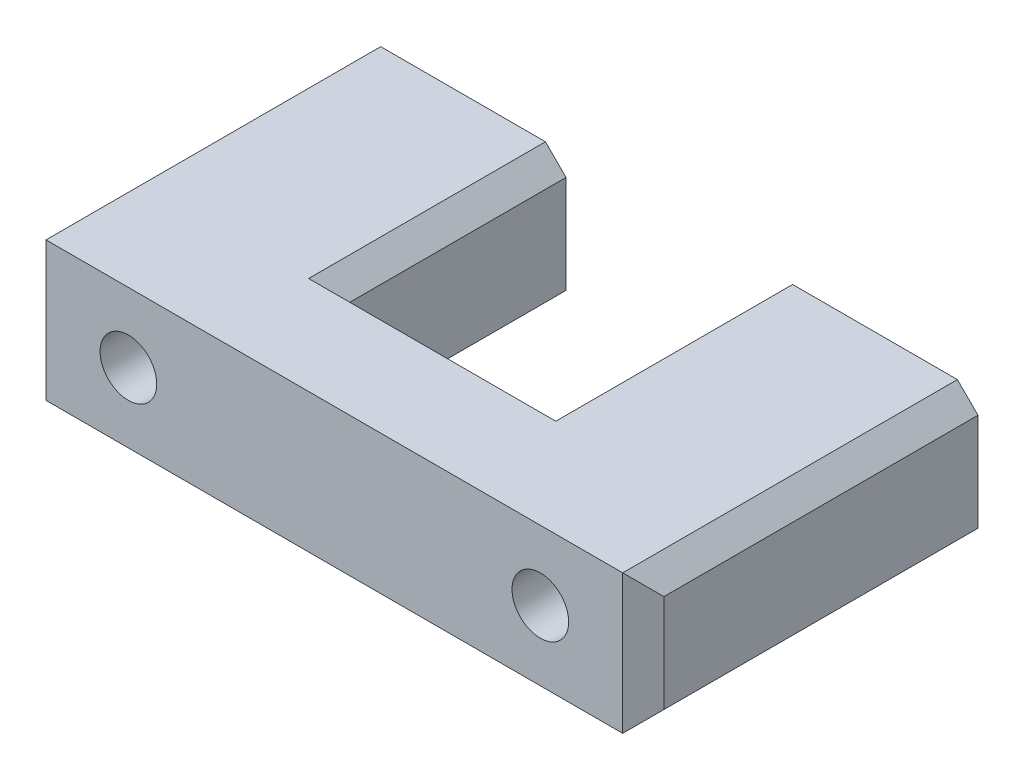
from build123d import *

# Parameters (mm, degrees)
SKETCH1_W           = 13.5
SKETCH1_H           = 60
SKETCH1_R           = 2.75
BOSS_EXTRUDE1_DEPTH = 32.5
SKETCH2_W           = 20
SKETCH2_H           = 21
CUT_EXTRUDE1_DEPTH  = 14.5
CHAMFER1_SIZE       = 2
CHAMFER2_SIZE       = 2


with BuildPart() as part:
    # Sketch1 → Boss-Extrude1 (new body)
    with BuildSketch(Plane(origin=(0, 0, 0), x_dir=(0, 1, 0), z_dir=(0, 0, 1))):
        Rectangle(SKETCH1_W, SKETCH1_H)
        with Locations((0, 20)):
            Circle(SKETCH1_R, mode=Mode.SUBTRACT)
        with Locations((0, -20)):
            Circle(SKETCH1_R, mode=Mode.SUBTRACT)
    extrude(amount=BOSS_EXTRUDE1_DEPTH)

    # Sketch2 → Cut-Extrude1 (cut, through all)
    with BuildSketch(Plane(origin=(0, 6.75, 0), x_dir=(-1, 0, 0), z_dir=(0, 1, 0))):
        with Locations((0, 10.5)):
            Rectangle(SKETCH2_W, SKETCH2_H)
    extrude(amount=-CUT_EXTRUDE1_DEPTH, mode=Mode.SUBTRACT)

    # Chamfer1
    chamfer1_edges = [part.edges().sort_by_distance(p)[0] for p in [
        (30, 0, 32.5),
        (30, 6.75, 16.25),
        (30, -6.75, 16.25),
        (-30, -6.75, 16.25),
        (-30, 6.75, 16.25),
        (-30, 0, 32.5),
    ]]
    chamfer(chamfer1_edges, length=CHAMFER1_SIZE)

    # Chamfer2
    chamfer2_edges = [part.edges().sort_by_distance(p)[0] for p in [
        (10, -6.75, 10.5),
        (0, -6.75, 21),
        (-10, -6.75, 10.5),
        (10, 6.75, 10.5),
        (-10, 6.75, 10.5),
        (0, 6.75, 21),
    ]]
    chamfer(chamfer2_edges, length=CHAMFER2_SIZE)


solid = part.part
